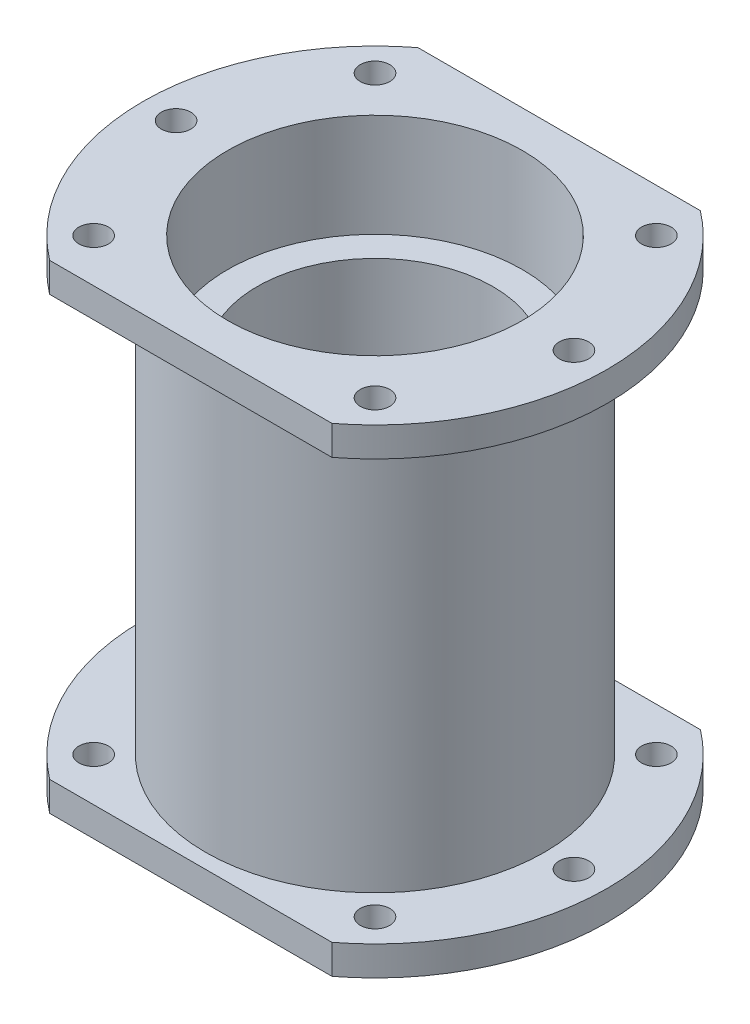
from build123d import *

# Parameters (mm, degrees)
SKETCH4_R           = 31.5
SKETCH4_R_2         = 21.5
SKETCH4_R_3         = 2
BOSS_EXTRUDE1_DEPTH = 4
SKETCH5_W           = 97.16267939
SKETCH5_H           = 14.406328081
SKETCH5_H_2         = 19.608613221
CUT_EXTRUDE1_DEPTH  = 66


with BuildPart() as part:
    # Sketch1 → Revolve1 (revolve)
    with BuildSketch(Plane.XY):
        Polygon((-12, 2.5), (-12, -2.5), (-16, -2.5), (-16, -18.5), (-20, -18.5), (-20, -32.5), (-23, -32.5), (-23, 32.5), (-20, 32.5), (-20, 18.5), (-16, 18.5), (-16, 2.5), align=None)
    revolve(axis=Axis((0, 75.096781517, 0), (0, -1, 0)))

    # Sketch4 → Boss-Extrude1 (add)
    with BuildSketch(Plane(origin=(0, 32.5, 0), x_dir=(1, 0, 0), z_dir=(0, 1, 0))):
        Circle(SKETCH4_R)
        Circle(SKETCH4_R_2, mode=Mode.SUBTRACT)
        with Locations((0, 27)):
            Circle(SKETCH4_R_3, mode=Mode.SUBTRACT)
        with Locations((19.091883092, 19.091883092)):
            Circle(SKETCH4_R_3, mode=Mode.SUBTRACT)
        with Locations((27, 0)):
            Circle(SKETCH4_R_3, mode=Mode.SUBTRACT)
        with Locations((19.091883092, -19.091883092)):
            Circle(SKETCH4_R_3, mode=Mode.SUBTRACT)
        with Locations((0, -27)):
            Circle(SKETCH4_R_3, mode=Mode.SUBTRACT)
        with Locations((-19.091883092, -19.091883092)):
            Circle(SKETCH4_R_3, mode=Mode.SUBTRACT)
        with Locations((-27, 0)):
            Circle(SKETCH4_R_3, mode=Mode.SUBTRACT)
        with Locations((-19.091883092, 19.091883092)):
            Circle(SKETCH4_R_3, mode=Mode.SUBTRACT)
    boss_extrude1 = extrude(amount=-BOSS_EXTRUDE1_DEPTH)

    # Mirror1: Boss-Extrude1 across plane
    add(boss_extrude1.mirror(Plane.ZX))

    # Sketch5 → Cut-Extrude1 (cut, through all)
    with BuildSketch(Plane(origin=(0, 32.5, 0), x_dir=(1, 0, 0), z_dir=(0, 1, 0))):
        with Locations((4.630564128, 32.20316404)):
            Rectangle(SKETCH5_W, SKETCH5_H)
        with Locations((4.630564128, -34.804306611)):
            Rectangle(SKETCH5_W, SKETCH5_H_2)
    extrude(amount=-CUT_EXTRUDE1_DEPTH, mode=Mode.SUBTRACT)


solid = part.part
